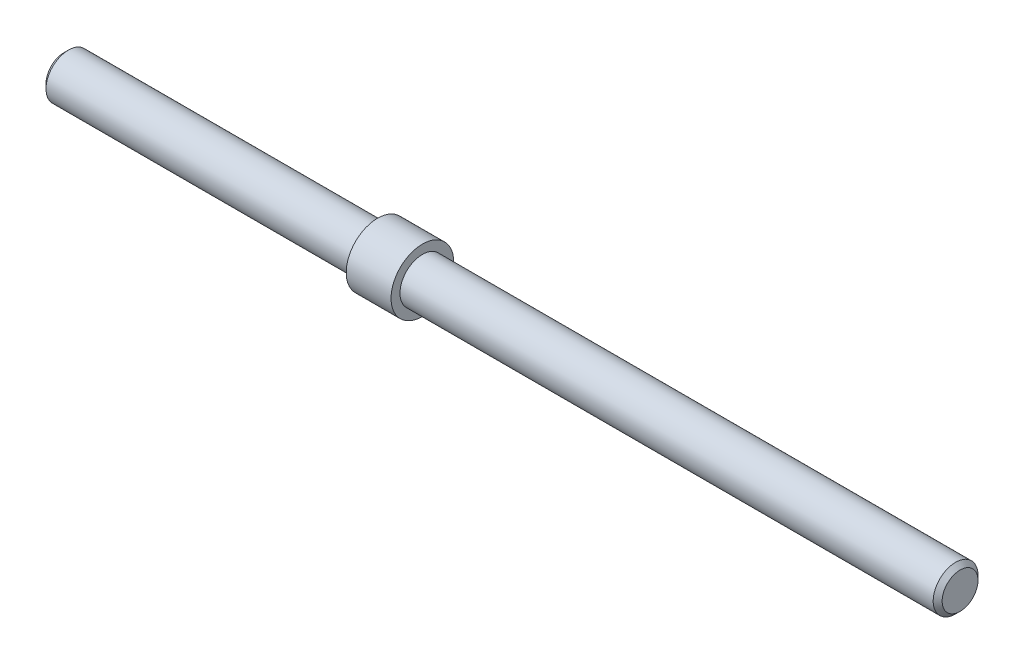
from build123d import *

# Parameters (mm, degrees)
SKETCH1_R           = 5
BOSS_EXTRUDE1_DEPTH = 200
CHAMFER1_SIZE       = 1
BOSS_EXTRUDE3_START = 70
SKETCH2_R           = 7
BOSS_EXTRUDE3_DEPTH = 10


with BuildPart() as part:
    # Sketch1 → Boss-Extrude1 (new body)
    with BuildSketch(Plane(origin=(0, 0, 0), x_dir=(0, 0, -1), z_dir=(1, 0, 0))):
        Circle(SKETCH1_R)
    extrude(amount=BOSS_EXTRUDE1_DEPTH)

    # Chamfer1
    chamfer1_edges = [part.edges().sort_by_distance(p)[0] for p in [
        (0, 0, 5),
        (200, 0, 5),
    ]]
    chamfer(chamfer1_edges, length=CHAMFER1_SIZE)

    # Sketch2 → Boss-Extrude3 (add)
    with BuildSketch(Plane(origin=(0, 0, 0), x_dir=(0, 0, -1), z_dir=(1, 0, 0)).offset(BOSS_EXTRUDE3_START)):
        Circle(SKETCH2_R)
    extrude(amount=BOSS_EXTRUDE3_DEPTH)


solid = part.part
